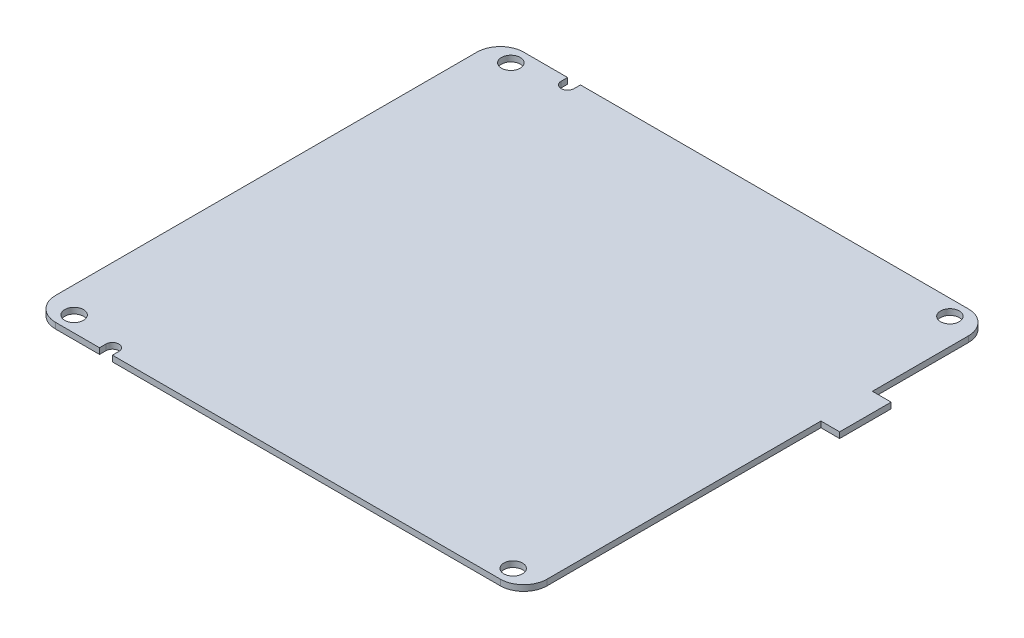
from build123d import *

# Parameters (mm, degrees)
SKETCH1_W                  = 105
SKETCH1_H                  = 100
SKETCH1_W_2                = 4
SKETCH1_H_2                = 11
MAIN_PCB_DEPTH             = 1.25
MAIN_PCB_ROUNDED_CORNERS_R = 5
MAIN_PCB_HOLES_REACH       = 3.25
SKETCH2_R                  = 2
SKETCH2_R_2                = 1.375


with BuildPart() as part:
    # Sketch1 → Main PCB (new body)
    with BuildSketch(Plane(origin=(0, 0, 0), x_dir=(1, 0, 0), z_dir=(0, 1, 0))):
        Rectangle(SKETCH1_W, SKETCH1_H)
        with Locations((54.5, 19)):
            Rectangle(SKETCH1_W_2, SKETCH1_H_2)
    extrude(amount=MAIN_PCB_DEPTH)

    # Main PCB rounded corners
    main_pcb_rounded_corners_edges = [part.edges().sort_by_distance(p)[0] for p in [
        (52.5, 0.625, 50),
        (-52.5, 0.625, 50),
        (-52.5, 0.625, -50),
        (52.5, 0.625, -50),
    ]]
    fillet(main_pcb_rounded_corners_edges, radius=MAIN_PCB_ROUNDED_CORNERS_R)

    # Sketch2 → Main PCB holes (cut, up to next)
    with BuildSketch(Plane(origin=(0, 1.25, 0), x_dir=(1, 0, 0), z_dir=(0, 1, 0)), mode=Mode.PRIVATE) as main_pcb_holes_sk1:
        with Locations((-46.9, 46.65)):
            Circle(SKETCH2_R)
    main_pcb_holes_tool1 = extrude(main_pcb_holes_sk1.sketch, amount=-MAIN_PCB_HOLES_REACH, mode=Mode.PRIVATE) & part.part
    add(main_pcb_holes_tool1.solids().sort_by_distance((-46.9, 1.25, -46.65))[0], mode=Mode.SUBTRACT)
    # Sketch2 → Main PCB holes (cut, up to next)
    with BuildSketch(Plane(origin=(0, 1.25, 0), x_dir=(1, 0, 0), z_dir=(0, 1, 0)), mode=Mode.PRIVATE) as main_pcb_holes_sk2:
        with Locations((46.9, 46.65)):
            Circle(SKETCH2_R)
    main_pcb_holes_tool2 = extrude(main_pcb_holes_sk2.sketch, amount=-MAIN_PCB_HOLES_REACH, mode=Mode.PRIVATE) & part.part
    add(main_pcb_holes_tool2.solids().sort_by_distance((46.9, 1.25, -46.65))[0], mode=Mode.SUBTRACT)
    # Sketch2 → Main PCB holes (cut, up to next)
    with BuildSketch(Plane(origin=(0, 1.25, 0), x_dir=(1, 0, 0), z_dir=(0, 1, 0)), mode=Mode.PRIVATE) as main_pcb_holes_sk3:
        with Locations((46.9, -46.65)):
            Circle(SKETCH2_R)
    main_pcb_holes_tool3 = extrude(main_pcb_holes_sk3.sketch, amount=-MAIN_PCB_HOLES_REACH, mode=Mode.PRIVATE) & part.part
    add(main_pcb_holes_tool3.solids().sort_by_distance((46.9, 1.25, 46.65))[0], mode=Mode.SUBTRACT)
    # Sketch2 → Main PCB holes (cut, up to next)
    with BuildSketch(Plane(origin=(0, 1.25, 0), x_dir=(1, 0, 0), z_dir=(0, 1, 0)), mode=Mode.PRIVATE) as main_pcb_holes_sk4:
        with Locations((-46.9, -46.65)):
            Circle(SKETCH2_R)
    main_pcb_holes_tool4 = extrude(main_pcb_holes_sk4.sketch, amount=-MAIN_PCB_HOLES_REACH, mode=Mode.PRIVATE) & part.part
    add(main_pcb_holes_tool4.solids().sort_by_distance((-46.9, 1.25, 46.65))[0], mode=Mode.SUBTRACT)
    # Sketch2 → Main PCB holes (cut, up to next)
    with BuildSketch(Plane(origin=(0, 1.25, 0), x_dir=(1, 0, 0), z_dir=(0, 1, 0)), mode=Mode.PRIVATE) as main_pcb_holes_sk5:
        with Locations((-36.75, -48.625)):
            Circle(SKETCH2_R_2)
    main_pcb_holes_tool5 = extrude(main_pcb_holes_sk5.sketch, amount=-MAIN_PCB_HOLES_REACH, mode=Mode.PRIVATE) & part.part
    add(main_pcb_holes_tool5.solids().sort_by_distance((-36.75, 1.25, 48.625))[0], mode=Mode.SUBTRACT)
    # Sketch2 → Main PCB holes (cut, up to next)
    with BuildSketch(Plane(origin=(0, 1.25, 0), x_dir=(1, 0, 0), z_dir=(0, 1, 0)), mode=Mode.PRIVATE) as main_pcb_holes_sk6:
        with BuildLine():
            ThreePointArc((-36.75, -50), (-37.722271824, -49.597271824), (-38.125, -48.625))
            Line((-38.125, -48.625), (-38.125, -50))
            Line((-38.125, -50), (-36.75, -50))
        make_face()
    main_pcb_holes_tool6 = extrude(main_pcb_holes_sk6.sketch, amount=-MAIN_PCB_HOLES_REACH, mode=Mode.PRIVATE) & part.part
    add(main_pcb_holes_tool6.solids().sort_by_distance((-37.817869, 1.25, 49.692869))[0], mode=Mode.SUBTRACT)
    # Sketch2 → Main PCB holes (cut, up to next)
    with BuildSketch(Plane(origin=(0, 1.25, 0), x_dir=(1, 0, 0), z_dir=(0, 1, 0)), mode=Mode.PRIVATE) as main_pcb_holes_sk7:
        with BuildLine():
            Line((-35.375, -50), (-35.375, -48.625))
            ThreePointArc((-35.375, -48.625), (-35.777728176, -49.597271824), (-36.75, -50))
            Line((-36.75, -50), (-35.375, -50))
        make_face()
    main_pcb_holes_tool7 = extrude(main_pcb_holes_sk7.sketch, amount=-MAIN_PCB_HOLES_REACH, mode=Mode.PRIVATE) & part.part
    add(main_pcb_holes_tool7.solids().sort_by_distance((-35.682131, 1.25, 49.692869))[0], mode=Mode.SUBTRACT)
    # Sketch2 → Main PCB holes (cut, up to next)
    with BuildSketch(Plane(origin=(0, 1.25, 0), x_dir=(1, 0, 0), z_dir=(0, 1, 0)), mode=Mode.PRIVATE) as main_pcb_holes_sk8:
        with BuildLine():
            Line((-36.75, 50), (-38.125, 50))
            Line((-38.125, 50), (-38.125, 48.625))
            ThreePointArc((-38.125, 48.625), (-37.722271824, 49.597271824), (-36.75, 50))
        make_face()
    main_pcb_holes_tool8 = extrude(main_pcb_holes_sk8.sketch, amount=-MAIN_PCB_HOLES_REACH, mode=Mode.PRIVATE) & part.part
    add(main_pcb_holes_tool8.solids().sort_by_distance((-37.817869, 1.25, -49.692869))[0], mode=Mode.SUBTRACT)
    # Sketch2 → Main PCB holes (cut, up to next)
    with BuildSketch(Plane(origin=(0, 1.25, 0), x_dir=(1, 0, 0), z_dir=(0, 1, 0)), mode=Mode.PRIVATE) as main_pcb_holes_sk9:
        with Locations((-36.75, 48.625)):
            Circle(SKETCH2_R_2)
    main_pcb_holes_tool9 = extrude(main_pcb_holes_sk9.sketch, amount=-MAIN_PCB_HOLES_REACH, mode=Mode.PRIVATE) & part.part
    add(main_pcb_holes_tool9.solids().sort_by_distance((-36.75, 1.25, -48.625))[0], mode=Mode.SUBTRACT)
    # Sketch2 → Main PCB holes (cut, up to next)
    with BuildSketch(Plane(origin=(0, 1.25, 0), x_dir=(1, 0, 0), z_dir=(0, 1, 0)), mode=Mode.PRIVATE) as main_pcb_holes_sk10:
        with BuildLine():
            Line((-35.375, 50), (-36.75, 50))
            ThreePointArc((-36.75, 50), (-35.777728176, 49.597271824), (-35.375, 48.625))
            Line((-35.375, 48.625), (-35.375, 50))
        make_face()
    main_pcb_holes_tool10 = extrude(main_pcb_holes_sk10.sketch, amount=-MAIN_PCB_HOLES_REACH, mode=Mode.PRIVATE) & part.part
    add(main_pcb_holes_tool10.solids().sort_by_distance((-35.682131, 1.25, -49.692869))[0], mode=Mode.SUBTRACT)


solid = part.part
